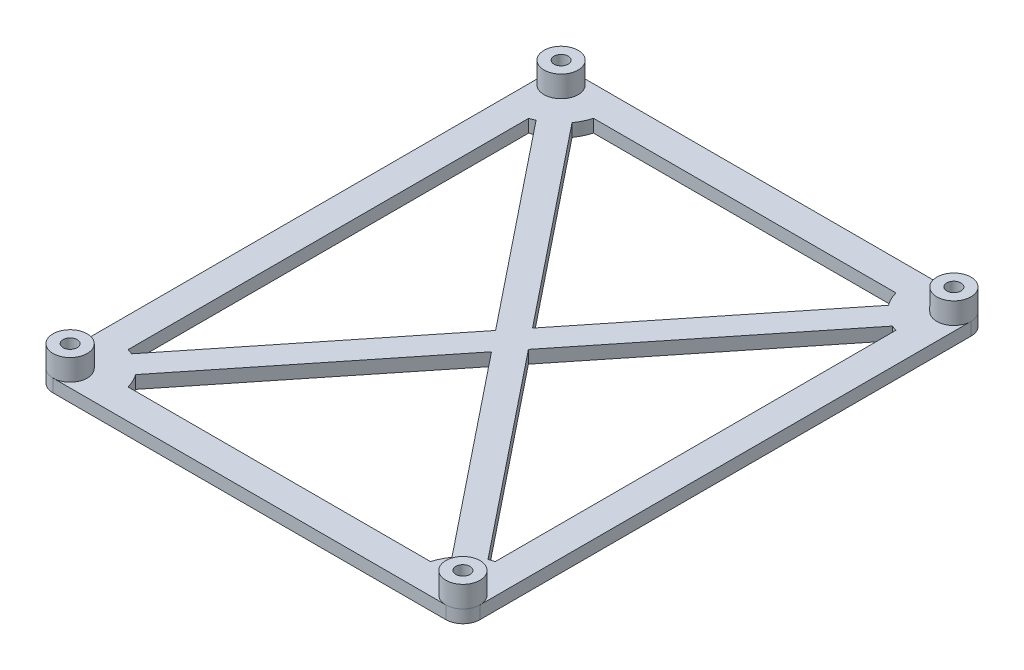
from build123d import *

# Parameters (mm, degrees)
SKETCH1_W             = 100
SKETCH1_H             = 123
BOSS_EXTRUDE1_DEPTH   = 3
SKETCH2_R             = 4
BOSS_EXTRUDE2_DEPTH   = 5
CUT_EXTRUDE1_DEPTH    = 80.418196907
FILLET1_R             = 4
BOSS_EXTRUDE3_DEPTH   = 3
M4X0_7_TAPPED_HOLE1_D = 3.3


with BuildPart() as part:
    # Sketch1 → Boss-Extrude1 (new body)
    with BuildSketch(Plane(origin=(0, 0, 0), x_dir=(1, 0, 0), z_dir=(0, 1, 0))):
        Rectangle(SKETCH1_W, SKETCH1_H)
    extrude(amount=BOSS_EXTRUDE1_DEPTH)

    # Sketch2 → Boss-Extrude2 (add)
    with BuildSketch(Plane(origin=(0, 3, 0), x_dir=(1, 0, 0), z_dir=(0, 1, 0))):
        with Locations(Location((46, 57.5, 0), (0, 0, 90))):
            Circle(SKETCH2_R)
        with Locations(Location((46, -57.5, 0), (0, 0, 270))):
            Circle(SKETCH2_R)
        with Locations(Location((-46, -57.5, 0), (0, 0, 270))):
            Circle(SKETCH2_R)
        with Locations(Location((-46, 57.5, 0), (0, 0, 90))):
            Circle(SKETCH2_R)
    extrude(amount=BOSS_EXTRUDE2_DEPTH)

    # Sketch3 → Cut-Extrude1 (cut, through all)
    with BuildSketch(Plane(origin=(0, 3, 0), x_dir=(1, 0, 0), z_dir=(0, 1, 0))):
        with BuildLine():
            Line((-43, 46.916994756), (-43, -46.916994756))
            ThreePointArc((-43, -46.916994756), (-38.221825407, -49.721825407), (-35.416994756, -54.5))
            Line((-35.416994756, -54.5), (35.416994756, -54.5))
            ThreePointArc((35.416994756, -54.5), (38.221825407, -49.721825407), (43, -46.916994756))
            Line((43, -46.916994756), (43, 46.916994756))
            ThreePointArc((43, 46.916994756), (38.221825407, 49.721825407), (35.416994756, 54.5))
            Line((35.416994756, 54.5), (-35.416994756, 54.5))
            ThreePointArc((-35.416994756, 54.5), (-38.221825407, 49.721825407), (-43, 46.916994756))
        make_face()
    extrude(amount=-CUT_EXTRUDE1_DEPTH, mode=Mode.SUBTRACT)

    # Fillet1
    fillet1_edges = [part.edges().sort_by_distance(p)[0] for p in [
        (-50, 1.5, -61.5),
        (50, 1.5, -61.5),
        (50, 1.5, 61.5),
        (-50, 1.5, 61.5),
    ]]
    fillet(fillet1_edges, radius=FILLET1_R)

    # Sketch4 → Boss-Extrude3 (add, through all)
    with BuildSketch(Plane(origin=(0, 3, 0), x_dir=(1, 0, 0), z_dir=(0, 1, 0))):
        Polygon((-43.657393572, 59.374085143), (-48.342606428, 55.625914857), (-3.841874542, 0), (-48.342606428, -55.625914857), (-43.657393572, -59.374085143), (0, -4.802343178), (43.657393572, -59.374085143), (48.342606428, -55.625914857), (3.841874542, 0), (48.342606428, 55.625914857), (43.657393572, 59.374085143), (0, 4.802343178), align=None)
    extrude(amount=-BOSS_EXTRUDE3_DEPTH)

    # M4x0.7 Tapped Hole1 (through all)
    with Locations(Plane(origin=(0, 8, 0), x_dir=(1, 0, 0), z_dir=(0, 1, 0))):
        with Locations((-46, 57.5), (46, 57.5), (46, -57.5), (-46, -57.5)):
            Hole(M4X0_7_TAPPED_HOLE1_D / 2)


solid = part.part
